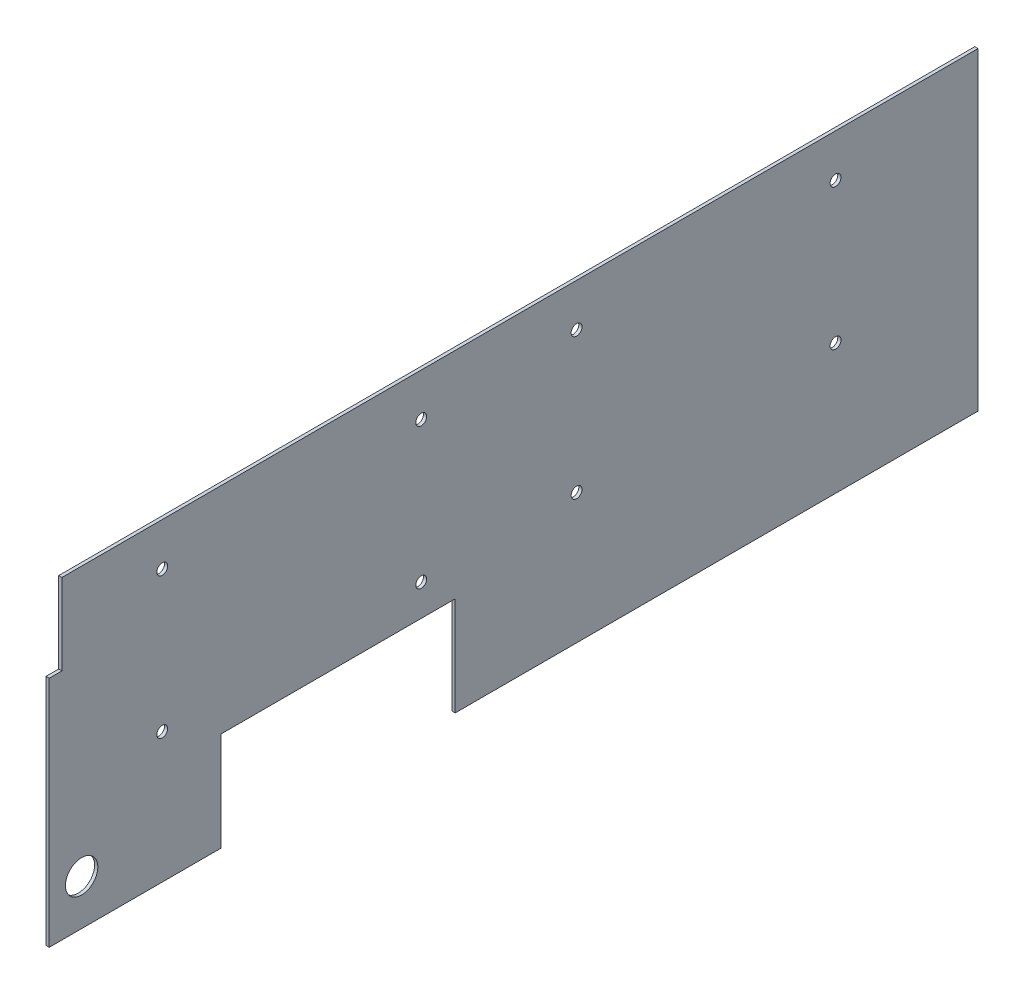
from build123d import *

# Parameters (mm, degrees)
SKETCH1_W           = 455.468181772
SKETCH1_H           = 153.9875
BOSS_EXTRUDE1_DEPTH = 1.5875
SKETCH2_R           = 7.9375
SKETCH2_W           = 6.205681772
SKETCH2_H           = 39.6875
SKETCH2_W_2         = 114.949431772
SKETCH2_H_2         = 48.476800861
CUT_EXTRUDE1_DEPTH  = 1.5875
SKETCH3_R           = 2.667
CUT_EXTRUDE2_DEPTH  = 1.5875


with BuildPart() as part:
    # Sketch1 → Boss-Extrude1 (new body)
    with BuildSketch(Plane(origin=(0, 0, 0), x_dir=(0, 0, -1), z_dir=(1, 0, 0))):
        Rectangle(SKETCH1_W, SKETCH1_H)
    extrude(amount=BOSS_EXTRUDE1_DEPTH)

    # Sketch2 → Cut-Extrude1 (cut)
    with BuildSketch(Plane.ZY):
        with Locations((211.859090932, -54.76875)):
            Circle(SKETCH2_R)
        with Locations((224.63125, 57.15)):
            Rectangle(SKETCH2_W, SKETCH2_H)
        with Locations((86.121875, -52.75534957)):
            Rectangle(SKETCH2_W_2, SKETCH2_H_2)
    extrude(amount=-CUT_EXTRUDE1_DEPTH, mode=Mode.SUBTRACT)

    # Sketch3 → Cut-Extrude2 (cut)
    with BuildSketch(Plane(origin=(1.5875, 0, 0), x_dir=(0, 0, -1), z_dir=(1, 0, 0))):
        with Locations((157.884090886, 55.959375)):
            Circle(SKETCH3_R)
        with Locations((157.884090886, -13.096875)):
            Circle(SKETCH3_R)
        with Locations((30.884090886, -13.096875)):
            Circle(SKETCH3_R)
        with Locations((-45.315909114, -13.096875)):
            Circle(SKETCH3_R)
        with Locations((-172.315909114, -13.096875)):
            Circle(SKETCH3_R)
        with Locations((-172.315909114, 55.959375)):
            Circle(SKETCH3_R)
        with Locations((-45.315909114, 55.959375)):
            Circle(SKETCH3_R)
        with Locations((30.884090886, 55.959375)):
            Circle(SKETCH3_R)
    extrude(amount=-CUT_EXTRUDE2_DEPTH, mode=Mode.SUBTRACT)


solid = part.part
